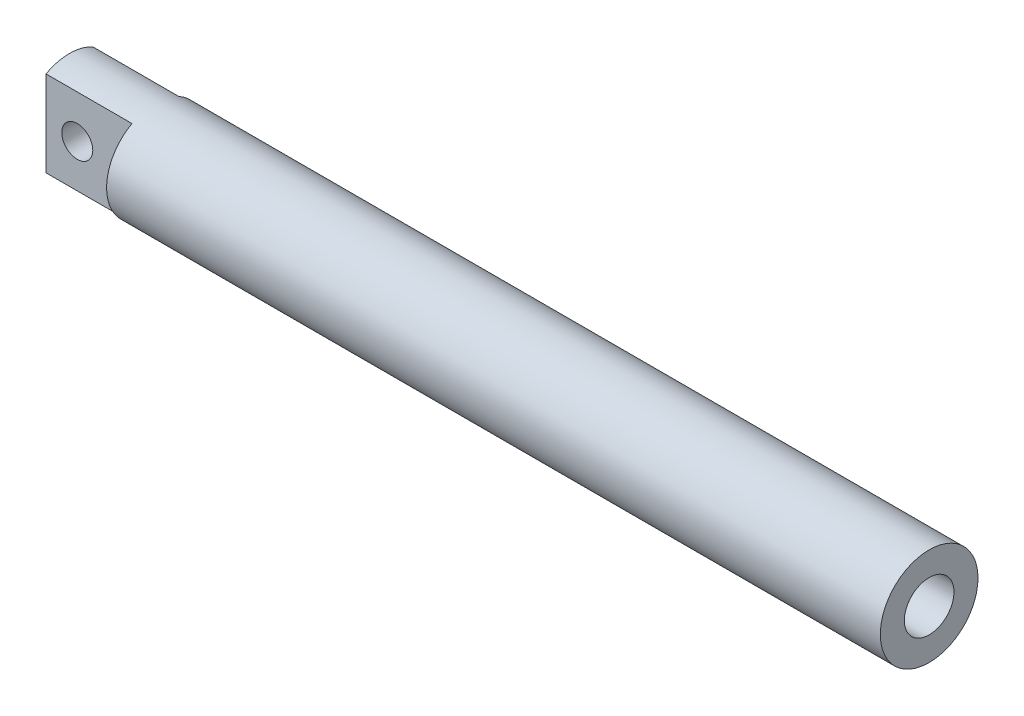
from build123d import *

# Parameters (mm, degrees)
CROQUIS1_R              = 12.5
SALIENTE_EXTRUIR1_DEPTH = 220
CROQUIS2_W              = 7.84246484
CROQUIS2_H              = 28.503577792
CROQUIS2_W_2            = 7.563798576
CROQUIS2_H_2            = 29.299767116
CORTAR_EXTRUIR1_DEPTH   = 22
CROQUIS3_R              = 3.96875
CORTAR_EXTRUIR2_DEPTH   = 22
CROQUIS4_R              = 6.35
CORTAR_EXTRUIR3_DEPTH   = 140


with BuildPart() as part:
    # Croquis1 → Saliente-Extruir1 (new body)
    with BuildSketch(Plane(origin=(0, 0, 0), x_dir=(0, 0, -1), z_dir=(1, 0, 0))):
        Circle(CROQUIS1_R)
    extrude(amount=SALIENTE_EXTRUIR1_DEPTH)

    # Croquis2 → Cortar-Extruir1 (cut)
    with BuildSketch(Plane.ZY):
        with Locations((-9.92123242, 0.389210904)):
            Rectangle(CROQUIS2_W, CROQUIS2_H)
        with Locations((9.781899288, 0.787305566)):
            Rectangle(CROQUIS2_W_2, CROQUIS2_H_2)
    extrude(amount=-CORTAR_EXTRUIR1_DEPTH, mode=Mode.SUBTRACT)

    # Croquis3 → Cortar-Extruir2 (cut)
    with BuildSketch(Plane.XY.offset(6)):
        with Locations((8, 0)):
            Circle(CROQUIS3_R)
    extrude(amount=-CORTAR_EXTRUIR2_DEPTH, mode=Mode.SUBTRACT)

    # Croquis4 → Cortar-Extruir3 (cut)
    with BuildSketch(Plane(origin=(220, 0, 0), x_dir=(0, 0, -1), z_dir=(1, 0, 0))):
        Circle(CROQUIS4_R)
    extrude(amount=-CORTAR_EXTRUIR3_DEPTH, mode=Mode.SUBTRACT)


solid = part.part
